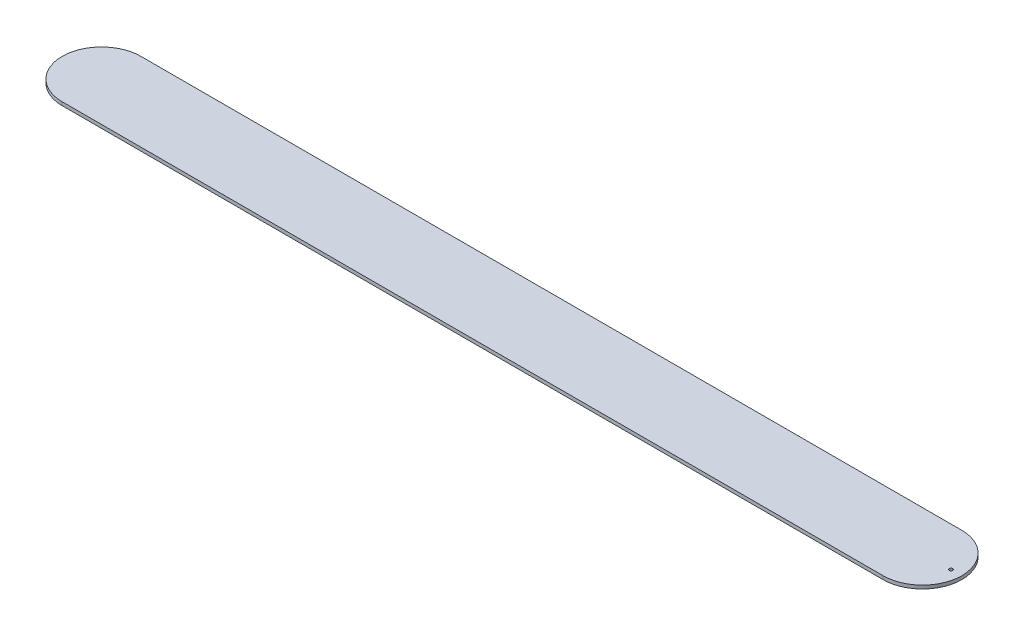
from build123d import *

# Parameters (mm, degrees)
BOSS_EXTRUDE1_DEPTH   = 3
F_3_0MM_DOWEL_HOLE1_D = 3


with BuildPart() as part:
    # Sketch1 → Boss-Extrude1 (new body)
    with BuildSketch(Plane(origin=(0, 0, 0), x_dir=(-1, 0, 0), z_dir=(0, 1, 0))):
        with BuildLine():
            Line((-360, -34.499989605), (360.00000001, -34.499989605))
            ThreePointArc((360.00000001, -34.499989605), (394.499995555, 5.94e-06), (360.00000001, 34.500001485))
            Line((360.00000001, 34.500001485), (-360, 34.500001485))
            ThreePointArc((-360, 34.500001485), (-394.499995545, 5.94e-06), (-360, -34.499989605))
        make_face()
    extrude(amount=BOSS_EXTRUDE1_DEPTH)

    # Ø3.0mm Dowel Hole1 (through all)
    with Locations(Plane(origin=(0, 3, 0), x_dir=(1, 0, 0), z_dir=(0, 1, 0))):
        with Locations((385.000000048, 0)):
            Hole(F_3_0MM_DOWEL_HOLE1_D / 2)


solid = part.part
